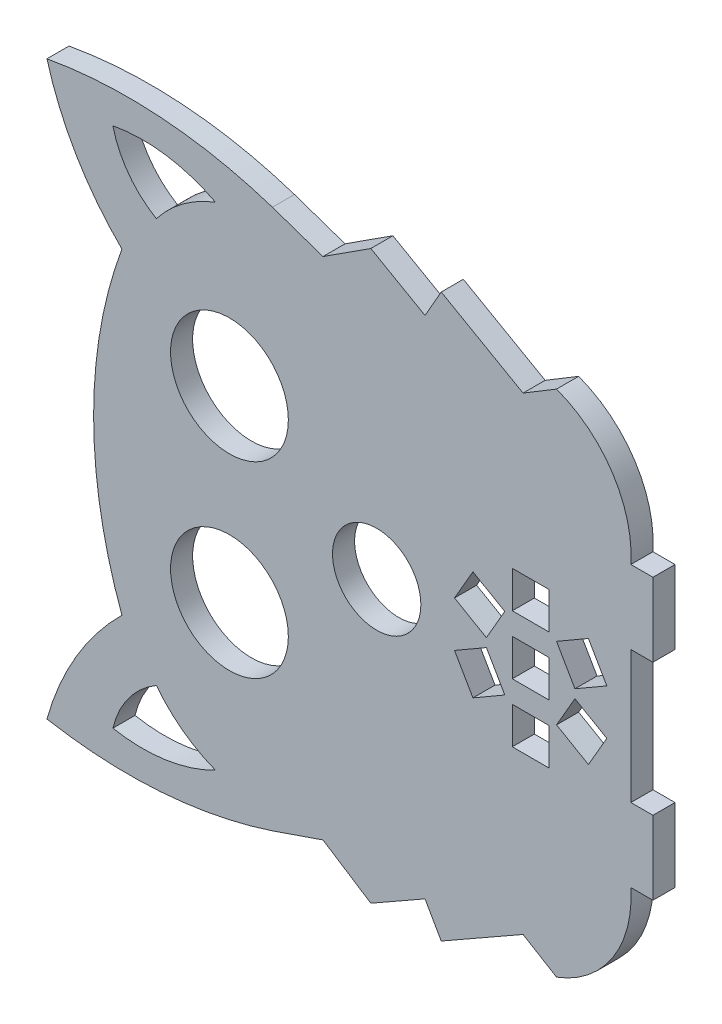
from build123d import *

# Parameters (mm, degrees)
SKETCH2_R           = 8
SKETCH2_R_2         = 6
SKETCH2_W           = 5
SKETCH2_H           = 5
BOSS_EXTRUDE1_DEPTH = 3


with BuildPart() as part:
    # Sketch2 → Boss-Extrude1 (new body)
    with BuildSketch(Plane.XY):
        with BuildLine():
            Line((81.032103119, 50.181312), (81.032103119, 60.181312))
            Line((81.032103119, 60.181312), (78.032103119, 60.181312))
            ThreePointArc((78.032103119, 60.181312), (75.569321499, 69.649967364), (67.936161846, 75.770065518))
            Line((67.936161846, 75.770065518), (63.389132962, 73.023833254))
            Line((63.389132962, 73.023833254), (52.27464227, 79.356930255))
            Line((52.27464227, 79.356930255), (50.074247047, 75.495269488))
            Line((50.074247047, 75.495269488), (42.709956252, 79.691482274))
            Line((42.709956252, 79.691482274), (36.212476018, 75.495269488))
            Line((36.212476018, 75.495269488), (29.342622159, 77.861804263))
            ThreePointArc((29.342622159, 77.861804263), (14.166162437, 80.849682425), (-1.279201176, 80.017163065))
            ThreePointArc((-1.279201176, 80.017163065), (2.677054283, 70.700200378), (8.902417187, 62.718809041))
            ThreePointArc((8.902417187, 62.718809041), (5.05730693, 41.181312), (8.902417187, 19.643814959))
            ThreePointArc((8.902417187, 19.643814959), (2.677054283, 11.662423622), (-1.279201176, 2.345460935))
            ThreePointArc((-1.279201176, 2.345460935), (14.166162437, 1.512941575), (29.342622159, 4.500819737))
            Line((29.342622159, 4.500819737), (36.212476018, 6.867354512))
            Line((36.212476018, 6.867354512), (42.709956252, 2.671141726))
            Line((42.709956252, 2.671141726), (50.074247047, 6.867354512))
            Line((50.074247047, 6.867354512), (52.27464227, 3.005693745))
            Line((52.27464227, 3.005693745), (63.389132962, 9.338790746))
            Line((63.389132962, 9.338790746), (67.936161846, 6.592558482))
            ThreePointArc((67.936161846, 6.592558482), (75.569321499, 12.712656636), (78.032103119, 22.181312))
            Line((78.032103119, 22.181312), (81.032103119, 22.181312))
            Line((81.032103119, 22.181312), (81.032103119, 32.181312))
            Line((81.032103119, 32.181312), (78.032103119, 32.181312))
            Line((78.032103119, 32.181312), (78.032103119, 50.181312))
            Line((78.032103119, 50.181312), (81.032103119, 50.181312))
        make_face()
        with Locations((23.507028058, 53.931312)):
            Circle(SKETCH2_R, mode=Mode.SUBTRACT)
        with Locations((43.507028058, 41.181312)):
            Circle(SKETCH2_R_2, mode=Mode.SUBTRACT)
        with Locations((23.507028058, 28.431312)):
            Circle(SKETCH2_R, mode=Mode.SUBTRACT)
        with Locations((64.423022125, 41.181312)):
            Rectangle(SKETCH2_W, SKETCH2_H, mode=Mode.SUBTRACT)
        with Locations((64.423022125, 33.181312)):
            Rectangle(SKETCH2_W, SKETCH2_H, mode=Mode.SUBTRACT)
        Polygon((72.266288865, 48.59637551), (67.936161846, 46.09637551), (70.436161846, 41.766248491), (74.766288865, 44.266248491), align=None, mode=Mode.SUBTRACT)
        Polygon((67.936161846, 36.266248491), (72.266288865, 33.766248491), (74.766288865, 38.09637551), (70.436161846, 40.596375509), align=None, mode=Mode.SUBTRACT)
        with Locations((64.423022125, 49.181312)):
            Rectangle(SKETCH2_W, SKETCH2_H, mode=Mode.SUBTRACT)
        Polygon((56.579755385, 33.766248491), (60.909882404, 36.266248491), (58.409882404, 40.59637551), (54.079755385, 38.09637551), align=None, mode=Mode.SUBTRACT)
        Polygon((60.909882404, 46.09637551), (56.579755385, 48.596375509), (54.079755385, 44.266248491), (58.409882404, 41.766248491), align=None, mode=Mode.SUBTRACT)
        with BuildLine():
            ThreePointArc((21.611730632, 74.586477389), (14.814545044, 76.765459524), (7.678288301, 76.612049032))
            ThreePointArc((7.678288301, 76.612049032), (9.811410227, 72.018941841), (13.580912618, 68.636975763))
            ThreePointArc((13.580912618, 68.636975763), (17.183726984, 72.168659356), (21.611730632, 74.586477389))
        make_face(mode=Mode.SUBTRACT)
        with BuildLine():
            ThreePointArc((7.678288301, 5.750574968), (9.811410227, 10.343682159), (13.580912618, 13.725648237))
            ThreePointArc((13.580912618, 13.725648237), (17.183726984, 10.193964644), (21.611730632, 7.776146611))
            ThreePointArc((21.611730632, 7.776146611), (14.814545044, 5.597164476), (7.678288301, 5.750574968))
        make_face(mode=Mode.SUBTRACT)
    extrude(amount=BOSS_EXTRUDE1_DEPTH)


solid = part.part
